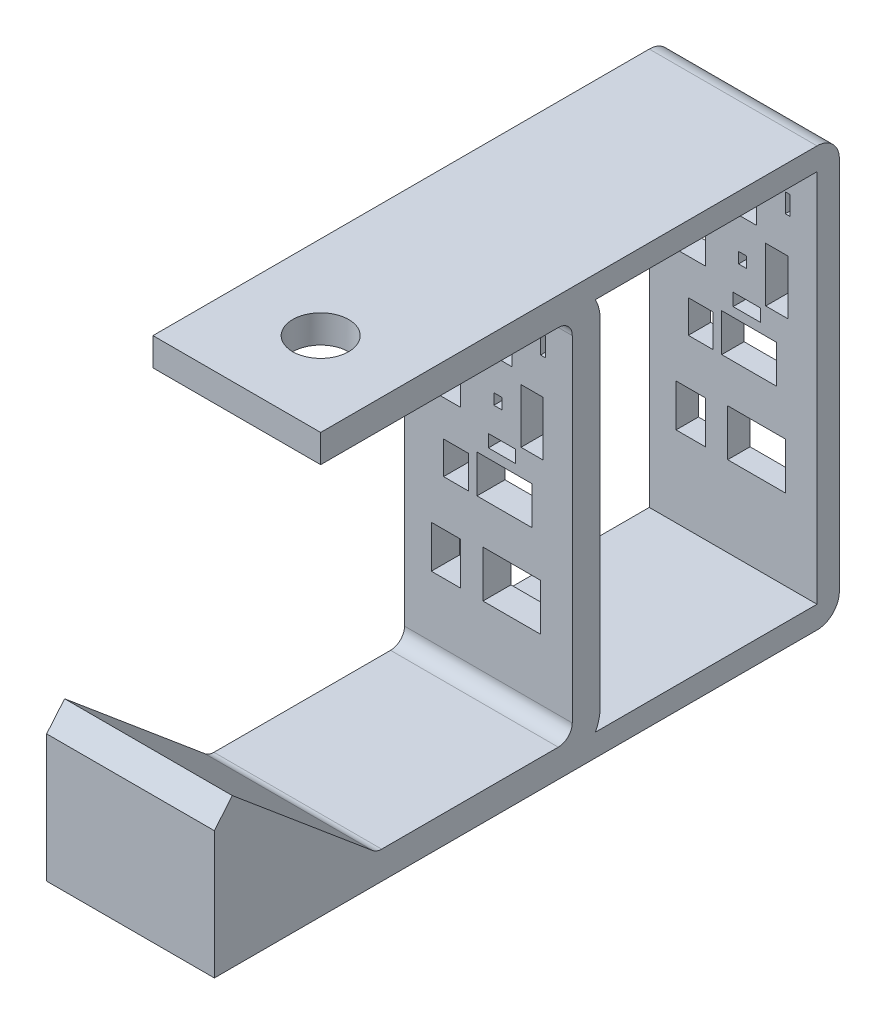
from build123d import *

# Parameters (mm, degrees)
BASE_EXTRUDE_THIN_DEPTH        = 19.05
CUT_EXTRUDE1_REACH             = 97.25
SKETCH2_R                      = 6.35
BOSS_EXTRUDE1_START            = -19.05
BOSS_EXTRUDE1_DEPTH            = 38.1
EXTRUDE_THIN1_DEPTH            = 38.1
CUT_EXTRUDE2_REACH             = 89.648
SKETCH4_W                      = 1.110971389
SKETCH4_H                      = 4.320444291
SKETCH4_W_2                    = 1.851618982
SKETCH4_H_2                    = 2.46882531
SKETCH4_W_3                    = 12.467567812
SKETCH4_H_3                    = 8.640888583
SKETCH4_W_4                    = 7.776799724
SKETCH4_H_4                    = 11.356596423
SKETCH4_W_5                    = 13.08477414
SKETCH4_H_5                    = 10.61594883
SKETCH4_W_6                    = 6.665828335
SKETCH4_H_6                    = 9.628418706
SKETCH4_W_7                    = 5.616577579
SKETCH4_H_7                    = 7.406475928
SKETCH4_W_8                    = 9.011212379
SKETCH4_H_8                    = 6.665828335
SKETCH4_W_9                    = 6.172063273
SKETCH4_H_9                    = 2.839149106
SKETCH4_W_10                   = 4.999371251
SKETCH4_H_10                   = 12.344126546
CUT_EXTRUDE2_DIRECTION_2_DEPTH = 55.324508946
FILLET1_R                      = 5.08


with BuildPart() as part:
    # Sketch1 → Base-Extrude-Thin (new body, symmetric)
    with BuildSketch(Plane(origin=(0, 0, 0), x_dir=(0, 0, -1), z_dir=(1, 0, 0))):
        with BuildLine():
            Line((-77.216478592, 27.494340102), (-45.335245167, 0.742808893))
            ThreePointArc((-45.335245167, 0.742808893), (-44.380308461, 0.191475929), (-43.294394506, 0))
            Line((-43.294394506, 0), (-3.175, 0))
            ThreePointArc((-3.175, 0), (-0.92993597, 0.92993597), (0, 3.175))
            Line((0, 3.175), (0, 79.375))
            ThreePointArc((0, 79.375), (-0.92993597, 81.62006403), (-3.175, 82.55))
            Line((-3.175, 82.55), (-57.15, 82.55))
            Line((-57.15, 82.55), (-57.15, 88.9))
            Line((-57.15, 88.9), (-3.175, 88.9))
            ThreePointArc((-3.175, 88.9), (3.560192091, 86.110192091), (6.35, 79.375))
            Line((6.35, 79.375), (6.35, 3.175))
            ThreePointArc((6.35, 3.175), (3.560192091, -3.560192091), (-3.175, -6.35))
            Line((-3.175, -6.35), (-43.294394506, -6.35))
            ThreePointArc((-43.294394506, -6.35), (-46.552136371, -5.775572213), (-49.416946488, -4.121573321))
            Line((-49.416946488, -4.121573321), (-81.298179914, 22.629957888))
            Line((-81.298179914, 22.629957888), (-77.216478592, 27.494340102))
        make_face()
    extrude(amount=BASE_EXTRUDE_THIN_DEPTH, both=True)

    # Sketch2 → Cut-Extrude1 (cut, up to next)
    with BuildSketch(Plane(origin=(0, 88.9, 0), x_dir=(-1, 0, 0), z_dir=(0, 1, 0)), mode=Mode.PRIVATE) as cut_extrude1_sk1:
        with Locations((0, 38.1)):
            Circle(SKETCH2_R)
    cut_extrude1_tool1 = extrude(cut_extrude1_sk1.sketch, amount=-CUT_EXTRUDE1_REACH, mode=Mode.PRIVATE) & part.part
    add(cut_extrude1_tool1.solids().sort_by_distance((0, 88.9, 38.1))[0], mode=Mode.SUBTRACT)

    # Sketch3 → Boss-Extrude1 (add)
    with BuildSketch(Plane(origin=(0, 0, 0), x_dir=(0, 0, -1), z_dir=(1, 0, 0)).offset(BOSS_EXTRUDE1_START)):
        with BuildLine():
            Line((-49.416946488, -4.121573321), (-81.298179914, 22.629957888))
            Line((-81.298179914, 22.629957888), (-81.298179914, -6.35))
            Line((-81.298179914, -6.35), (-43.294394506, -6.35))
            ThreePointArc((-43.294394506, -6.35), (-46.552136371, -5.775572213), (-49.416946488, -4.121573321))
        make_face()
    extrude(amount=BOSS_EXTRUDE1_DEPTH)

    # Sketch5 → Extrude-Thin1 (add, through all)
    with BuildSketch(Plane(origin=(19.05, 0, 0), x_dir=(0, 0, -1), z_dir=(1, 0, 0))):
        Polygon((-3.175, 88.9), (60.674508946, 88.9), (60.674508946, -6.35), (-3.175, -6.35), (-3.175, -1.27), (55.594508946, -1.27), (55.594508946, 83.82), (-3.175, 83.82), align=None)
    extrude(amount=-EXTRUDE_THIN1_DEPTH)

    # Sketch4 → Cut-Extrude2 (cut, up to next)
    with BuildSketch(Plane(origin=(0, 0, -6.35), x_dir=(-1, 0, 0), z_dir=(0, 0, -1)), mode=Mode.PRIVATE) as cut_extrude2_sk1:
        with Locations((-12.40584718, 74.110376614)):
            Rectangle(SKETCH4_W, SKETCH4_H)
    cut_extrude2_tool1 = extrude(cut_extrude2_sk1.sketch, amount=-CUT_EXTRUDE2_REACH, mode=Mode.PRIVATE) & part.part
    add(cut_extrude2_tool1.solids().sort_by_distance((12.405847, 74.110377, -6.35))[0], mode=Mode.SUBTRACT)
    # Sketch4 → Cut-Extrude2 (cut, up to next)
    with BuildSketch(Plane(origin=(0, 0, -6.35), x_dir=(-1, 0, 0), z_dir=(0, 0, -1)), mode=Mode.PRIVATE) as cut_extrude2_sk2:
        with Locations((-2.160222146, 58.001291471)):
            Rectangle(SKETCH4_W_2, SKETCH4_H_2)
    cut_extrude2_tool2 = extrude(cut_extrude2_sk2.sketch, amount=-CUT_EXTRUDE2_REACH, mode=Mode.PRIVATE) & part.part
    add(cut_extrude2_tool2.solids().sort_by_distance((2.160222, 58.001291, -6.35))[0], mode=Mode.SUBTRACT)
    # Sketch4 → Cut-Extrude2 (cut, up to next)
    with BuildSketch(Plane(origin=(0, 0, -6.35), x_dir=(-1, 0, 0), z_dir=(0, 0, -1)), mode=Mode.PRIVATE) as cut_extrude2_sk3:
        with Locations((-3.641517331, 41.336720633)):
            Rectangle(SKETCH4_W_3, SKETCH4_H_3)
    cut_extrude2_tool3 = extrude(cut_extrude2_sk3.sketch, amount=-CUT_EXTRUDE2_REACH, mode=Mode.PRIVATE) & part.part
    add(cut_extrude2_tool3.solids().sort_by_distance((3.641517, 41.336721, -6.35))[0], mode=Mode.SUBTRACT)
    # Sketch4 → Cut-Extrude2 (cut, up to next)
    with BuildSketch(Plane(origin=(0, 0, -6.35), x_dir=(-1, 0, 0), z_dir=(0, 0, -1)), mode=Mode.PRIVATE) as cut_extrude2_sk4:
        with Locations((10.183904401, 58.248174002)):
            Rectangle(SKETCH4_W_4, SKETCH4_H_4)
    cut_extrude2_tool4 = extrude(cut_extrude2_sk4.sketch, amount=-CUT_EXTRUDE2_REACH, mode=Mode.PRIVATE) & part.part
    add(cut_extrude2_tool4.solids().sort_by_distance((-10.183904, 58.248174, -6.35))[0], mode=Mode.SUBTRACT)
    # Sketch4 → Cut-Extrude2 (cut, up to next)
    with BuildSketch(Plane(origin=(0, 0, -6.35), x_dir=(-1, 0, 0), z_dir=(0, 0, -1)), mode=Mode.PRIVATE) as cut_extrude2_sk5:
        with Locations((-5.307974415, 22.326765751)):
            Rectangle(SKETCH4_W_5, SKETCH4_H_5)
    cut_extrude2_tool5 = extrude(cut_extrude2_sk5.sketch, amount=-CUT_EXTRUDE2_REACH, mode=Mode.PRIVATE) & part.part
    add(cut_extrude2_tool5.solids().sort_by_distance((5.307974, 22.326766, -6.35))[0], mode=Mode.SUBTRACT)
    # Sketch4 → Cut-Extrude2 (cut, up to next)
    with BuildSketch(Plane(origin=(0, 0, -6.35), x_dir=(-1, 0, 0), z_dir=(0, 0, -1)), mode=Mode.PRIVATE) as cut_extrude2_sk6:
        with Locations((9.628418706, 21.833000689)):
            Rectangle(SKETCH4_W_6, SKETCH4_H_6)
    cut_extrude2_tool6 = extrude(cut_extrude2_sk6.sketch, amount=-CUT_EXTRUDE2_REACH, mode=Mode.PRIVATE) & part.part
    add(cut_extrude2_tool6.solids().sort_by_distance((-9.628419, 21.833001, -6.35))[0], mode=Mode.SUBTRACT)
    # Sketch4 → Cut-Extrude2 (cut, up to next)
    with BuildSketch(Plane(origin=(0, 0, -6.35), x_dir=(-1, 0, 0), z_dir=(0, 0, -1)), mode=Mode.PRIVATE) as cut_extrude2_sk7:
        with Locations((7.375615612, 40.719514305)):
            Rectangle(SKETCH4_W_7, SKETCH4_H_7)
    cut_extrude2_tool7 = extrude(cut_extrude2_sk7.sketch, amount=-CUT_EXTRUDE2_REACH, mode=Mode.PRIVATE) & part.part
    add(cut_extrude2_tool7.solids().sort_by_distance((-7.375616, 40.719514, -6.35))[0], mode=Mode.SUBTRACT)
    # Sketch4 → Cut-Extrude2 (cut, up to next)
    with BuildSketch(Plane(origin=(0, 0, -6.35), x_dir=(-1, 0, 0), z_dir=(0, 0, -1)), mode=Mode.PRIVATE) as cut_extrude2_sk8:
        with Locations((-0.802368225, 69.728211691)):
            Rectangle(SKETCH4_W_8, SKETCH4_H_8)
    cut_extrude2_tool8 = extrude(cut_extrude2_sk8.sketch, amount=-CUT_EXTRUDE2_REACH, mode=Mode.PRIVATE) & part.part
    add(cut_extrude2_tool8.solids().sort_by_distance((0.802368, 69.728212, -6.35))[0], mode=Mode.SUBTRACT)
    # Sketch4 → Cut-Extrude2 (cut, up to next)
    with BuildSketch(Plane(origin=(0, 0, -6.35), x_dir=(-1, 0, 0), z_dir=(0, 0, -1)), mode=Mode.PRIVATE) as cut_extrude2_sk9:
        with Locations((-3.086031637, 49.17524099)):
            Rectangle(SKETCH4_W_9, SKETCH4_H_9)
    cut_extrude2_tool9 = extrude(cut_extrude2_sk9.sketch, amount=-CUT_EXTRUDE2_REACH, mode=Mode.PRIVATE) & part.part
    add(cut_extrude2_tool9.solids().sort_by_distance((3.086032, 49.175241, -6.35))[0], mode=Mode.SUBTRACT)
    # Sketch4 → Cut-Extrude2 (cut, up to next)
    with BuildSketch(Plane(origin=(0, 0, -6.35), x_dir=(-1, 0, 0), z_dir=(0, 0, -1)), mode=Mode.PRIVATE) as cut_extrude2_sk10:
        with Locations((-9.906161554, 57.75440894)):
            Rectangle(SKETCH4_W_10, SKETCH4_H_10)
    cut_extrude2_tool10 = extrude(cut_extrude2_sk10.sketch, amount=-CUT_EXTRUDE2_REACH, mode=Mode.PRIVATE) & part.part
    add(cut_extrude2_tool10.solids().sort_by_distance((9.906162, 57.754409, -6.35))[0], mode=Mode.SUBTRACT)

    # Sketch4 → Cut-Extrude2 direction 2 (cut)
    with BuildSketch(Plane(origin=(0, 0, -6.35), x_dir=(-1, 0, 0), z_dir=(0, 0, -1))):
        with Locations((-12.40584718, 74.110376614)):
            Rectangle(SKETCH4_W, SKETCH4_H)
        with Locations((-2.160222146, 58.001291471)):
            Rectangle(SKETCH4_W_2, SKETCH4_H_2)
        with Locations((-3.641517331, 41.336720633)):
            Rectangle(SKETCH4_W_3, SKETCH4_H_3)
        with Locations((10.183904401, 58.248174002)):
            Rectangle(SKETCH4_W_4, SKETCH4_H_4)
        with Locations((-5.307974415, 22.326765751)):
            Rectangle(SKETCH4_W_5, SKETCH4_H_5)
        with Locations((9.628418706, 21.833000689)):
            Rectangle(SKETCH4_W_6, SKETCH4_H_6)
        with Locations((7.375615612, 40.719514305)):
            Rectangle(SKETCH4_W_7, SKETCH4_H_7)
        with Locations((-0.802368225, 69.728211691)):
            Rectangle(SKETCH4_W_8, SKETCH4_H_8)
        with Locations((-3.086031637, 49.17524099)):
            Rectangle(SKETCH4_W_9, SKETCH4_H_9)
        with Locations((-9.906161554, 57.75440894)):
            Rectangle(SKETCH4_W_10, SKETCH4_H_10)
    extrude(amount=CUT_EXTRUDE2_DIRECTION_2_DEPTH, mode=Mode.SUBTRACT)

    # Fillet1
    fillet1_edges = [part.edges().sort_by_distance(p)[0] for p in [
        (0, 88.9, -60.674508946),
        (0, -6.35, -60.674508946),
    ]]
    fillet(fillet1_edges, radius=FILLET1_R)


solid = part.part
